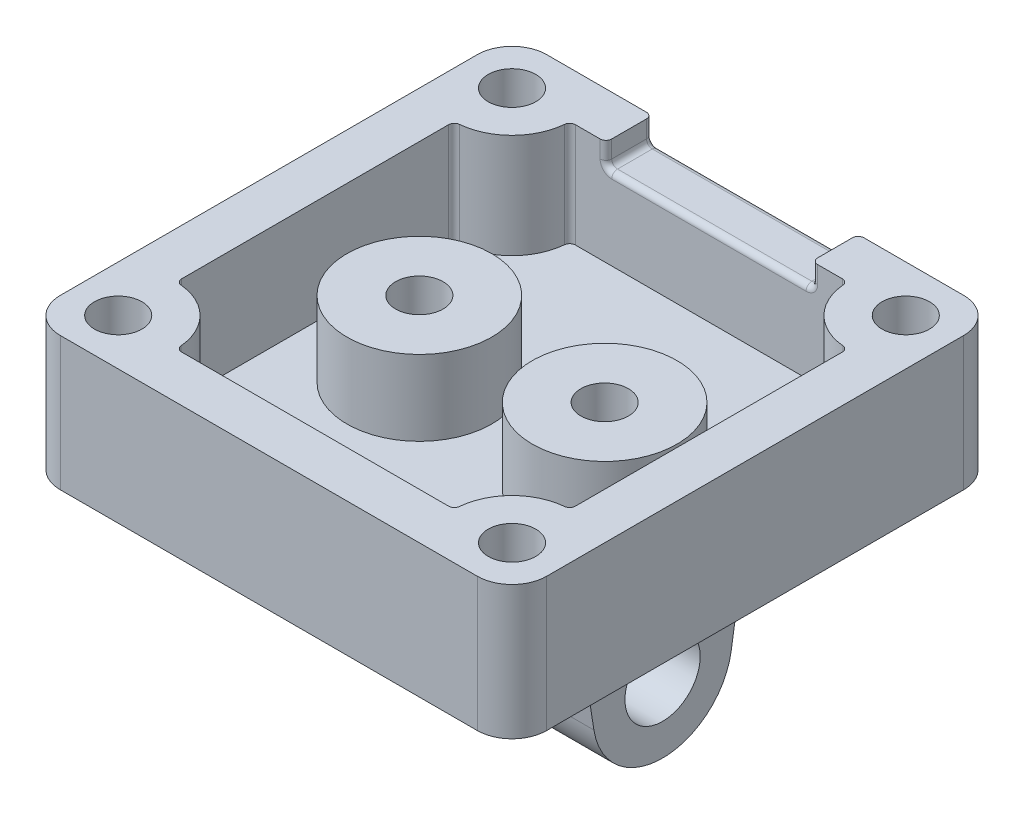
from build123d import *

# Parameters (mm, degrees)
SKETCH1_W           = 42
SKETCH1_H           = 42
BOSS_EXTRUDE1_DEPTH = 2.54
SKETCH2_W           = 42
SKETCH2_H           = 42
BOSS_EXTRUDE2_DEPTH = 9
SKETCH13_R          = 3.25
BOSS_EXTRUDE6_DEPTH = 13
SKETCH9_R           = 6.25
SKETCH9_R_2         = 2.05
BOSS_EXTRUDE5_DEPTH = 6.5
SKETCH10_R          = 2.05
CUT_EXTRUDE1_DEPTH  = 8
SKETCH12_W          = 17.78
SKETCH12_H          = 2
CUT_EXTRUDE2_DEPTH  = 4
FILLET1_R           = 3
FILLET2_R           = 0.5
FILLET3_R           = 3


with BuildPart() as part:
    # Sketch1 → Boss-Extrude1 (new body)
    with BuildSketch(Plane(origin=(0, 0, 0), x_dir=(1, 0, 0), z_dir=(0, 1, 0))):
        Rectangle(SKETCH1_W, SKETCH1_H)
    extrude(amount=BOSS_EXTRUDE1_DEPTH)

    # Sketch2 → Boss-Extrude2 (add)
    with BuildSketch(Plane(origin=(0, 2.54, 0), x_dir=(1, 0, 0), z_dir=(0, 1, 0))):
        Rectangle(SKETCH2_W, SKETCH2_H)
        with BuildLine():
            Line((-17, 11.522774425), (-17, -11.522774425))
            ThreePointArc((-17, -11.522774425), (-16.869274473, -11.859874356), (-16.545454545, -12.020704023))
            ThreePointArc((-16.545454545, -12.020704023), (-13.464466094, -13.464466094), (-12.020704023, -16.545454545))
            ThreePointArc((-12.020704023, -16.545454545), (-11.859874356, -16.869274473), (-11.522774425, -17))
            Line((-11.522774425, -17), (11.522774425, -17))
            ThreePointArc((11.522774425, -17), (11.859874356, -16.869274473), (12.020704023, -16.545454545))
            ThreePointArc((12.020704023, -16.545454545), (13.464466094, -13.464466094), (16.545454545, -12.020704023))
            ThreePointArc((16.545454545, -12.020704023), (16.869274473, -11.859874356), (17, -11.522774425))
            Line((17, -11.522774425), (17, 11.522774425))
            ThreePointArc((17, 11.522774425), (16.869274473, 11.859874356), (16.545454545, 12.020704023))
            ThreePointArc((16.545454545, 12.020704023), (13.464466094, 13.464466094), (12.020704023, 16.545454545))
            ThreePointArc((12.020704023, 16.545454545), (11.859874356, 16.869274473), (11.522774425, 17))
            Line((11.522774425, 17), (-11.522774425, 17))
            ThreePointArc((-11.522774425, 17), (-11.859874356, 16.869274473), (-12.020704023, 16.545454545))
            ThreePointArc((-12.020704023, 16.545454545), (-13.464466094, 13.464466094), (-16.545454545, 12.020704023))
            ThreePointArc((-16.545454545, 12.020704023), (-16.869274473, 11.859874356), (-17, 11.522774425))
        make_face(mode=Mode.SUBTRACT)
    extrude(amount=BOSS_EXTRUDE2_DEPTH)

    # Sketch13 → Boss-Extrude6 (add, symmetric)
    with BuildSketch(Plane(origin=(0, 0, 0), x_dir=(0, 0, -1), z_dir=(1, 0, 0))):
        with BuildLine():
            Line((-7.5, 0), (-5.927131841, -10))
            ThreePointArc((-5.927131841, -10), (0, -15.067740305), (5.927131841, -10))
            Line((5.927131841, -10), (7.5, 0))
            Line((7.5, 0), (-7.5, 0))
        make_face()
        with Locations((0, -9.067740305)):
            Circle(SKETCH13_R, mode=Mode.SUBTRACT)
    extrude(amount=BOSS_EXTRUDE6_DEPTH, both=True)

    # Sketch9 → Boss-Extrude5 (add)
    with BuildSketch(Plane(origin=(0, 2.54, 0), x_dir=(1, 0, 0), z_dir=(0, 1, 0))):
        with Locations((8, 0)):
            Circle(SKETCH9_R)
        with Locations((8, 0)):
            Circle(SKETCH9_R_2, mode=Mode.SUBTRACT)
        with Locations((-8, 0)):
            Circle(SKETCH9_R)
        with Locations((-8, 0)):
            Circle(SKETCH9_R_2, mode=Mode.SUBTRACT)
    extrude(amount=BOSS_EXTRUDE5_DEPTH)

    # Sketch10 → Cut-Extrude1 (cut)
    with BuildSketch(Plane(origin=(0, 11.54, 0), x_dir=(1, 0, 0), z_dir=(0, 1, 0))):
        with Locations((-17, 17)):
            Circle(SKETCH10_R)
        with Locations((17, 17)):
            Circle(SKETCH10_R)
        with Locations((-17, -17)):
            Circle(SKETCH10_R)
        with Locations((17, -17)):
            Circle(SKETCH10_R)
    extrude(amount=-CUT_EXTRUDE1_DEPTH, mode=Mode.SUBTRACT)

    # Sketch12 → Cut-Extrude2 (cut)
    with BuildSketch(Plane(origin=(0, 0, -21), x_dir=(-1, 0, 0), z_dir=(0, 0, -1))):
        with Locations((0, 10.54)):
            Rectangle(SKETCH12_W, SKETCH12_H)
    extrude(amount=-CUT_EXTRUDE2_DEPTH, mode=Mode.SUBTRACT)

    # Fillet1
    fillet1_edges = [part.edges().sort_by_distance(p)[0] for p in [
        (21, 5.77, 21),
        (-21, 5.77, 21),
        (-21, 5.77, -21),
        (21, 5.77, -21),
    ]]
    fillet(fillet1_edges, radius=FILLET1_R)

    # Fillet2
    fillet2_edges = [part.edges().sort_by_distance(p)[0] for p in [
        (8.89, 10.54, -21),
        (0, 9.54, -21),
        (-8.89, 10.54, -21),
        (0, 9.54, -17),
        (-8.89, 9.54, -19),
        (-8.89, 10.54, -17),
        (8.89, 10.54, -17),
        (8.89, 9.54, -19),
    ]]
    fillet(fillet2_edges, radius=FILLET2_R)

    # Fillet3
    fillet3_edges = [part.edges().sort_by_distance(p)[0] for p in [
        (0, 0, -7.5),
        (0, 0, 7.5),
    ]]
    fillet(fillet3_edges, radius=FILLET3_R)


solid = part.part
